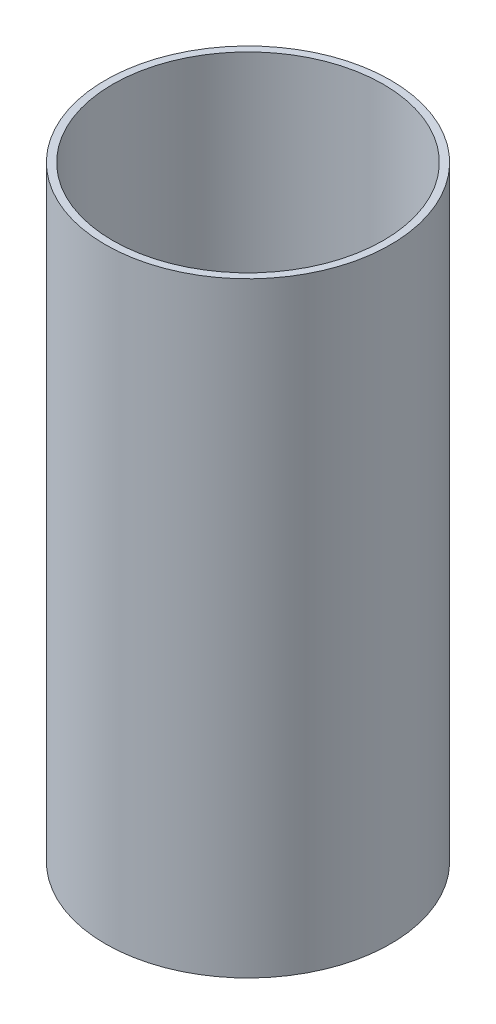
from build123d import *

# Parameters (mm, degrees)
SKETCH1_R           = 93.6625
SKETCH1_R_2         = 88.9
BOSS_EXTRUDE1_DEPTH = 198.882


with BuildPart() as part:
    # Sketch1 → Boss-Extrude1 (new body, symmetric)
    with BuildSketch(Plane(origin=(0, 0, 0), x_dir=(1, 0, 0), z_dir=(0, 1, 0))):
        Circle(SKETCH1_R)
        Circle(SKETCH1_R_2, mode=Mode.SUBTRACT)
    extrude(amount=BOSS_EXTRUDE1_DEPTH, both=True)


solid = part.part
